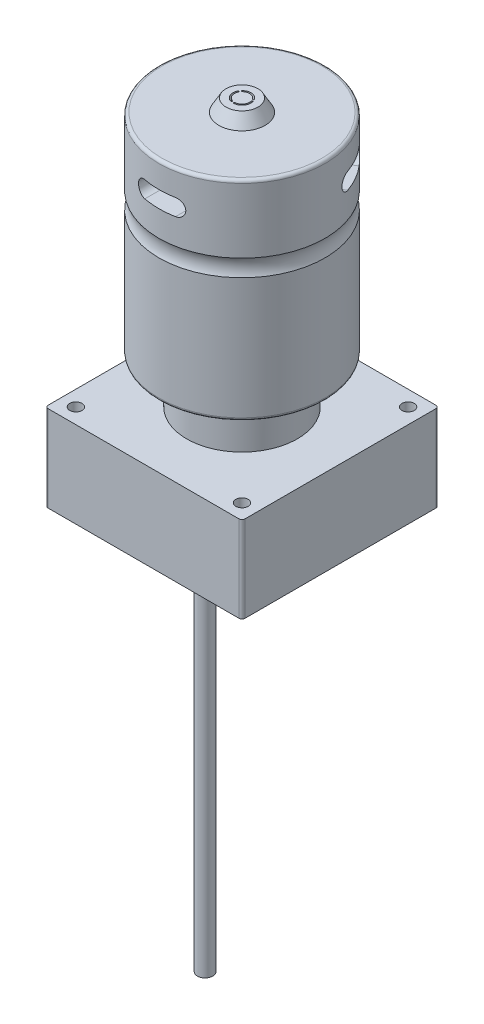
from build123d import *

# Parameters (mm, degrees)
BOSS_EXTRUDE1_DEPTH = 28
SKETCH2_R           = 18
BOSS_EXTRUDE2_DEPTH = 15
SKETCH3_R           = 27
BOSS_EXTRUDE3_DEPTH = 68
FILLET1_R           = 1
FILLET2_R           = 1
SKETCH4_R           = 2
CUT_EXTRUDE1_DEPTH  = 29
SKETCH5_R           = 2.5
BOSS_EXTRUDE4_DEPTH = 125
SKETCH7_R           = 7.5
BOSS_EXTRUDE5_DEPTH = 4
BOSS_EXTRUDE5_TAPER = 30
CUT_EXTRUDE2_DEPTH  = 10
CIRPATTERN1_COUNT   = 3
CUT_EXTRUDE3_DEPTH  = 10
CIRPATTERN2_COUNT   = 3


with BuildPart() as part:
    # Sketch1 → Boss-Extrude1 (new body)
    with BuildSketch(Plane(origin=(0, 0, 0), x_dir=(1, 0, 0), z_dir=(0, 1, 0))):
        with BuildLine():
            Line((-31, 32), (31, 32))
            ThreePointArc((31, 32), (31.707106781, 31.707106781), (32, 31))
            Line((32, 31), (32, -31))
            ThreePointArc((32, -31), (31.707106781, -31.707106781), (31, -32))
            Line((31, -32), (-31, -32))
            ThreePointArc((-31, -32), (-31.707106781, -31.707106781), (-32, -31))
            Line((-32, -31), (-32, 31))
            ThreePointArc((-32, 31), (-31.707106781, 31.707106781), (-31, 32))
        make_face()
    extrude(amount=BOSS_EXTRUDE1_DEPTH)

    # Sketch2 → Boss-Extrude2 (add)
    with BuildSketch(Plane(origin=(0, 28, 0), x_dir=(1, 0, 0), z_dir=(0, 1, 0))):
        Circle(SKETCH2_R)
    extrude(amount=BOSS_EXTRUDE2_DEPTH)

    # Sketch3 → Boss-Extrude3 (add)
    with BuildSketch(Plane(origin=(0, 43, 0), x_dir=(1, 0, 0), z_dir=(0, 1, 0))):
        Circle(SKETCH3_R)
    extrude(amount=BOSS_EXTRUDE3_DEPTH)

    # Fillet1
    fillet1_edges = [part.edges().sort_by_distance(p)[0] for p in [
        (-27, 43, 0),
    ]]
    fillet(fillet1_edges, radius=FILLET1_R)

    # Fillet2
    fillet2_edges = [part.edges().sort_by_distance(p)[0] for p in [
        (-27, 111, 0),
    ]]
    fillet(fillet2_edges, radius=FILLET2_R)

    # Sketch4 → Cut-Extrude1 (cut, through all)
    with BuildSketch(Plane(origin=(0, 28, 0), x_dir=(1, 0, 0), z_dir=(0, 1, 0))):
        with Locations((-27, 27)):
            Circle(SKETCH4_R)
        with Locations((27, 27)):
            Circle(SKETCH4_R)
        with Locations((27, -27)):
            Circle(SKETCH4_R)
        with Locations((-27, -27)):
            Circle(SKETCH4_R)
    extrude(amount=-CUT_EXTRUDE1_DEPTH, mode=Mode.SUBTRACT)

    # Sketch5 → Boss-Extrude4 (add)
    with BuildSketch(Plane.XZ):
        with Locations((0, 12)):
            Circle(SKETCH5_R)
    extrude(amount=BOSS_EXTRUDE4_DEPTH)

    # Sketch6 → Cut-Revolve1 (revolve, cut)
    with BuildSketch(Plane(origin=(0, 0, 0), x_dir=(0, 0, -1), z_dir=(1, 0, 0))):
        with BuildLine():
            Line((27, 88.942293347), (27, 83.446507899))
            ThreePointArc((27, 83.446507899), (26.371517202, 86.194400623), (27, 88.942293347))
        make_face()
    revolve(axis=Axis((0, 111, 0), (0, -1, 0)), mode=Mode.SUBTRACT)

    # Sketch7 → Boss-Extrude5 (add)
    with BuildSketch(Plane(origin=(0, 111, 0), x_dir=(1, 0, 0), z_dir=(0, 1, 0))):
        Circle(SKETCH7_R)
    extrude(amount=BOSS_EXTRUDE5_DEPTH, taper=BOSS_EXTRUDE5_TAPER)

    # Sketch8 → Cut-Extrude2 (cut)
    with BuildSketch(Plane.XY.offset(30)):
        with BuildLine():
            Line((-5.065984647, 102.694191022), (4.934015353, 102.694191022))
            ThreePointArc((4.934015353, 102.694191022), (7.628206376, 100), (4.934015353, 97.305808978))
            Line((4.934015353, 97.305808978), (-5.065984647, 97.305808978))
            ThreePointArc((-5.065984647, 97.305808978), (-7.760175669, 100), (-5.065984647, 102.694191022))
        make_face()
    cut_extrude2 = extrude(amount=-CUT_EXTRUDE2_DEPTH, mode=Mode.SUBTRACT)

    # CirPattern1: Cut-Extrude2 ×3 about axis
    cirpattern1_axis = Axis((0, 0, 0), (0, 1, 0))
    for i in range(1, CIRPATTERN1_COUNT):
        add(cut_extrude2.rotate(cirpattern1_axis, i * 360 / CIRPATTERN1_COUNT), mode=Mode.SUBTRACT)

    # Sketch9 → Cut-Extrude3 (cut)
    with BuildSketch(Plane(origin=(0, 115, 0), x_dir=(1, 0, 0), z_dir=(0, 1, 0))):
        with BuildLine():
            ThreePointArc((2.424806001, 1.617896807), (0.319254394, 2.897473184), (-2.014380463, 2.107022917))
            ThreePointArc((-2.014380463, 2.107022917), (-2.021480856, 1.791146289), (-1.705604229, 1.784045896))
            ThreePointArc((-1.705604229, 1.784045896), (0.270317179, 2.453331239), (2.053117296, 1.36989595))
            ThreePointArc((2.053117296, 1.36989595), (2.362962077, 1.308052026), (2.424806001, 1.617896807))
        make_face()
    cut_extrude3 = extrude(amount=-CUT_EXTRUDE3_DEPTH, mode=Mode.SUBTRACT)

    # CirPattern2: Cut-Extrude3 ×3 about axis
    cirpattern2_axis = Axis((0, 0, 0), (0, 1, 0))
    for i in range(1, CIRPATTERN2_COUNT):
        add(cut_extrude3.rotate(cirpattern2_axis, i * 360 / CIRPATTERN2_COUNT), mode=Mode.SUBTRACT)


solid = part.part
